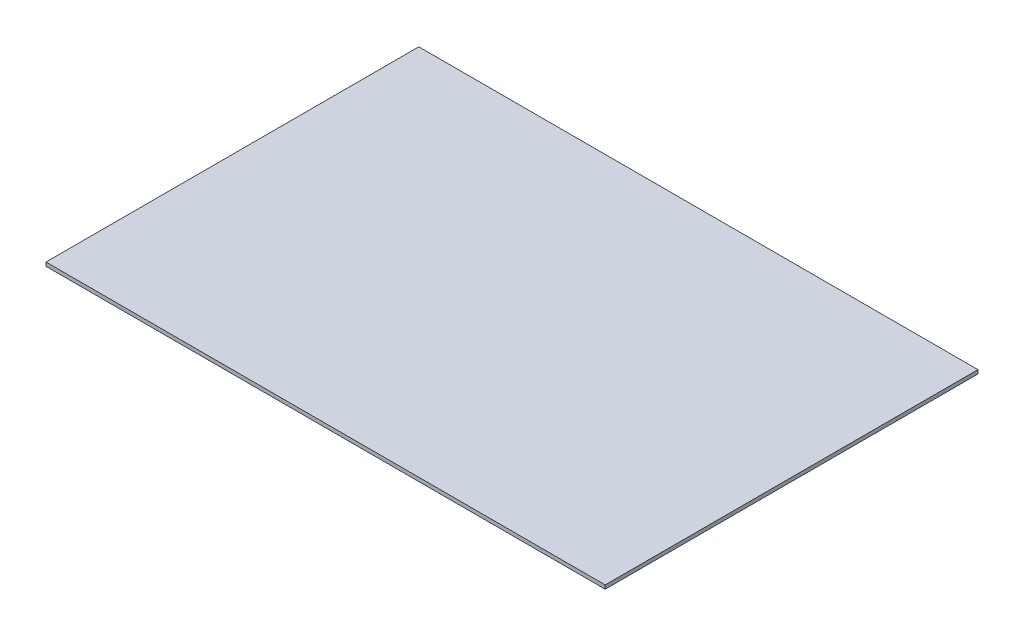
from build123d import *

# Parameters (mm, degrees)
SKETCH1_W      = 1500
SKETCH1_H      = 1000
EXTRUDE1_DEPTH = 10


with BuildPart() as part:
    # Sketch1 → Extrude1 (new body)
    with BuildSketch(Plane(origin=(0, 0, 0), x_dir=(1, 0, 0), z_dir=(0, 1, 0))):
        with Locations((-750, 500)):
            Rectangle(SKETCH1_W, SKETCH1_H)
    extrude(amount=EXTRUDE1_DEPTH)


solid = part.part
